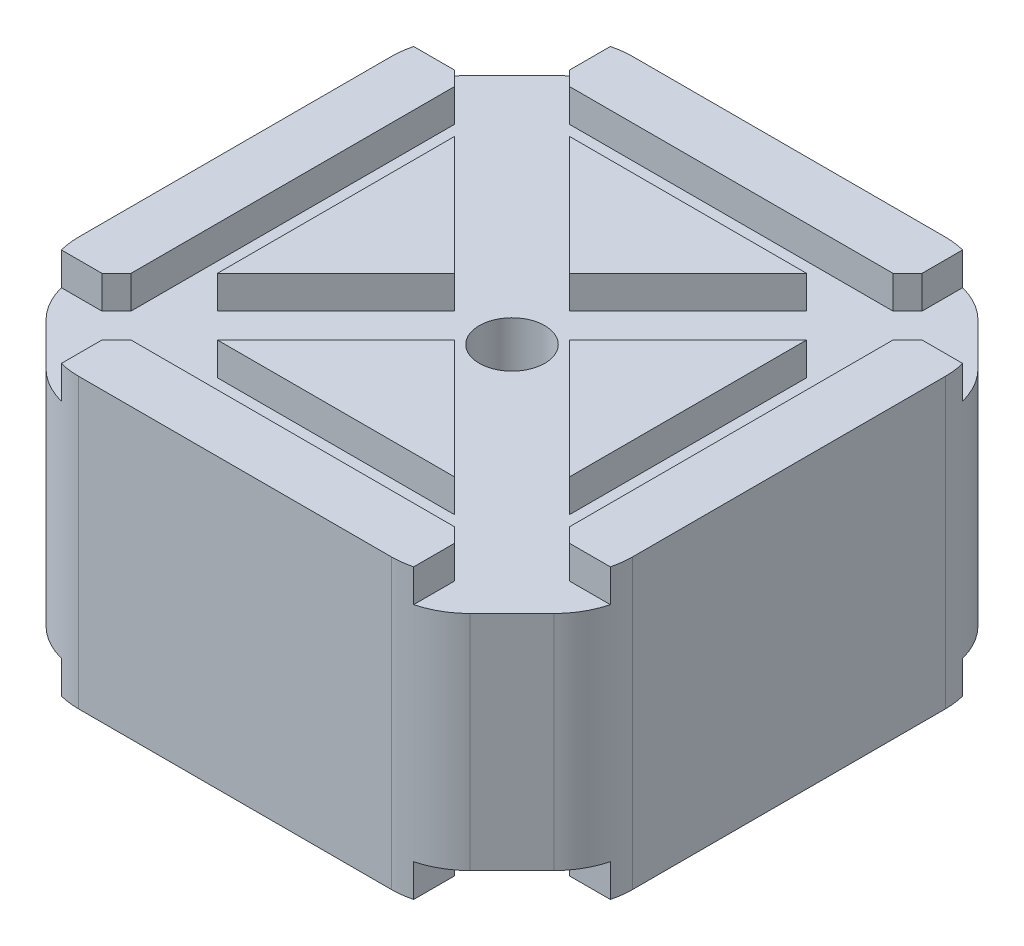
from build123d import *

# Parameters (mm, degrees)
BOSS_EXTRUDE1_DEPTH = 11
SKETCH18_W          = 3.3
SKETCH18_H          = 2.5
CUT_EXTRUDE10_DEPTH = 43.3
SKETCH19_W          = 3.3
SKETCH19_H          = 2.5
CUT_EXTRUDE11_DEPTH = 43.3
SKETCH20_W          = 6.221233688
SKETCH20_H          = 2.5
CUT_EXTRUDE12_DEPTH = 57.710616844
SKETCH21_W          = 6.221233688
SKETCH21_H          = 2.5
CUT_EXTRUDE13_DEPTH = 57.710616844
SKETCH22_R          = 2.5
CUT_EXTRUDE14_DEPTH = 9.5
CUT_EXTRUDE15_DEPTH = 20.5
FILLET8_R           = 6


with BuildPart() as part:
    # Sketch1 → Boss-Extrude1 (new body)
    with BuildSketch(Plane(origin=(0, 0, 0), x_dir=(1, 0, 0), z_dir=(0, 1, 0))):
        Polygon((-21.15, 16.750923472), (-16.750923472, 21.15), (16.750923472, 21.15), (21.15, 16.750923472), (21.15, -16.750923472), (16.750923472, -21.15), (-16.750923472, -21.15), (-21.15, -16.750923472), align=None)
    boss_extrude1 = extrude(amount=BOSS_EXTRUDE1_DEPTH)

    # Sketch18 → Cut-Extrude10 (cut, through all)
    with BuildSketch(Plane.XY.offset(21.15)):
        with Locations((15.100923472, 9.75)):
            Rectangle(SKETCH18_W, SKETCH18_H)
        with Locations((-15.100923472, 9.75)):
            Rectangle(SKETCH18_W, SKETCH18_H)
    cut_extrude10 = extrude(amount=-CUT_EXTRUDE10_DEPTH, mode=Mode.SUBTRACT)

    # Sketch19 → Cut-Extrude11 (cut, through all)
    with BuildSketch(Plane(origin=(21.15, 0, 0), x_dir=(0, 0, -1), z_dir=(1, 0, 0))):
        with Locations((-15.100923472, 9.75)):
            Rectangle(SKETCH19_W, SKETCH19_H)
        with Locations((15.100923472, 9.75)):
            Rectangle(SKETCH19_W, SKETCH19_H)
    cut_extrude11 = extrude(amount=-CUT_EXTRUDE11_DEPTH, mode=Mode.SUBTRACT)

    # Sketch20 → Cut-Extrude12 (cut, through all)
    with BuildSketch(Plane(origin=(18.950461736, 0, 18.950461736), x_dir=(0.707106781, 0, -0.707106781), z_dir=(0.707106781, 0, 0.707106781))):
        with Locations((0, 9.75)):
            Rectangle(SKETCH20_W, SKETCH20_H)
    cut_extrude12 = extrude(amount=-CUT_EXTRUDE12_DEPTH, mode=Mode.SUBTRACT)

    # Sketch21 → Cut-Extrude13 (cut, through all)
    with BuildSketch(Plane(origin=(-18.950461736, 0, 18.950461736), x_dir=(0.707106781, 0, 0.707106781), z_dir=(-0.707106781, 0, 0.707106781))):
        with Locations((0, 9.75)):
            Rectangle(SKETCH21_W, SKETCH21_H)
    cut_extrude13 = extrude(amount=-CUT_EXTRUDE13_DEPTH, mode=Mode.SUBTRACT)

    # Sketch22 → Cut-Extrude14 (cut, through all)
    with BuildSketch(Plane(origin=(0, 8.5, 0), x_dir=(1, 0, 0), z_dir=(0, 1, 0))):
        Circle(SKETCH22_R)
    cut_extrude14 = extrude(amount=-CUT_EXTRUDE14_DEPTH, mode=Mode.SUBTRACT)

    # Mirror1: Boss-Extrude1, Cut-Extrude10, Cut-Extrude11, Cut-Extrude12, Cut-Extrude13, Cut-Extrude14 across plane
    add(boss_extrude1.mirror(Plane(origin=(0, 0, 0), x_dir=(0, 0, 1), z_dir=(0, -1, 0))))
    add(cut_extrude10.mirror(Plane(origin=(0, 0, 0), x_dir=(0, 0, 1), z_dir=(0, -1, 0))), mode=Mode.SUBTRACT)
    add(cut_extrude11.mirror(Plane(origin=(0, 0, 0), x_dir=(0, 0, 1), z_dir=(0, -1, 0))), mode=Mode.SUBTRACT)
    add(cut_extrude12.mirror(Plane(origin=(0, 0, 0), x_dir=(0, 0, 1), z_dir=(0, -1, 0))), mode=Mode.SUBTRACT)
    add(cut_extrude13.mirror(Plane(origin=(0, 0, 0), x_dir=(0, 0, 1), z_dir=(0, -1, 0))), mode=Mode.SUBTRACT)
    add(cut_extrude14.mirror(Plane(origin=(0, 0, 0), x_dir=(0, 0, 1), z_dir=(0, -1, 0))), mode=Mode.SUBTRACT)

    # Sketch23 → Cut-Extrude15 (cut, through all)
    with BuildSketch(Plane(origin=(0, 8.5, 0), x_dir=(1, 0, 0), z_dir=(0, 1, 0))):
        Polygon((-21.15, -14.432485579), (-14.432485579, -21.15), (-16.750923472, -21.15), (-21.15, -16.750923472), align=None)
        Polygon((-21.15, 14.432485579), (-14.432485579, 21.15), (-16.750923472, 21.15), (-21.15, 16.750923472), align=None)
        Polygon((14.432485579, 21.15), (21.15, 14.432485579), (21.15, 16.750923472), (16.750923472, 21.15), align=None)
        Polygon((14.432485579, -21.15), (21.15, -14.432485579), (21.15, -16.750923472), (16.750923472, -21.15), align=None)
    extrude(amount=-CUT_EXTRUDE15_DEPTH, mode=Mode.SUBTRACT)

    # Fillet8
    fillet8_edges = [part.edges().sort_by_distance(p)[0] for p in [
        (14.432485579, 0, -21.15),
        (21.15, 0, -14.432485579),
        (-21.15, 0, -14.432485579),
        (-14.432485579, 0, -21.15),
        (-14.432485579, 0, 21.15),
        (-21.15, 0, 14.432485579),
        (21.15, 0, 14.432485579),
        (14.432485579, 0, 21.15),
    ]]
    fillet(fillet8_edges, radius=FILLET8_R)


solid = part.part
